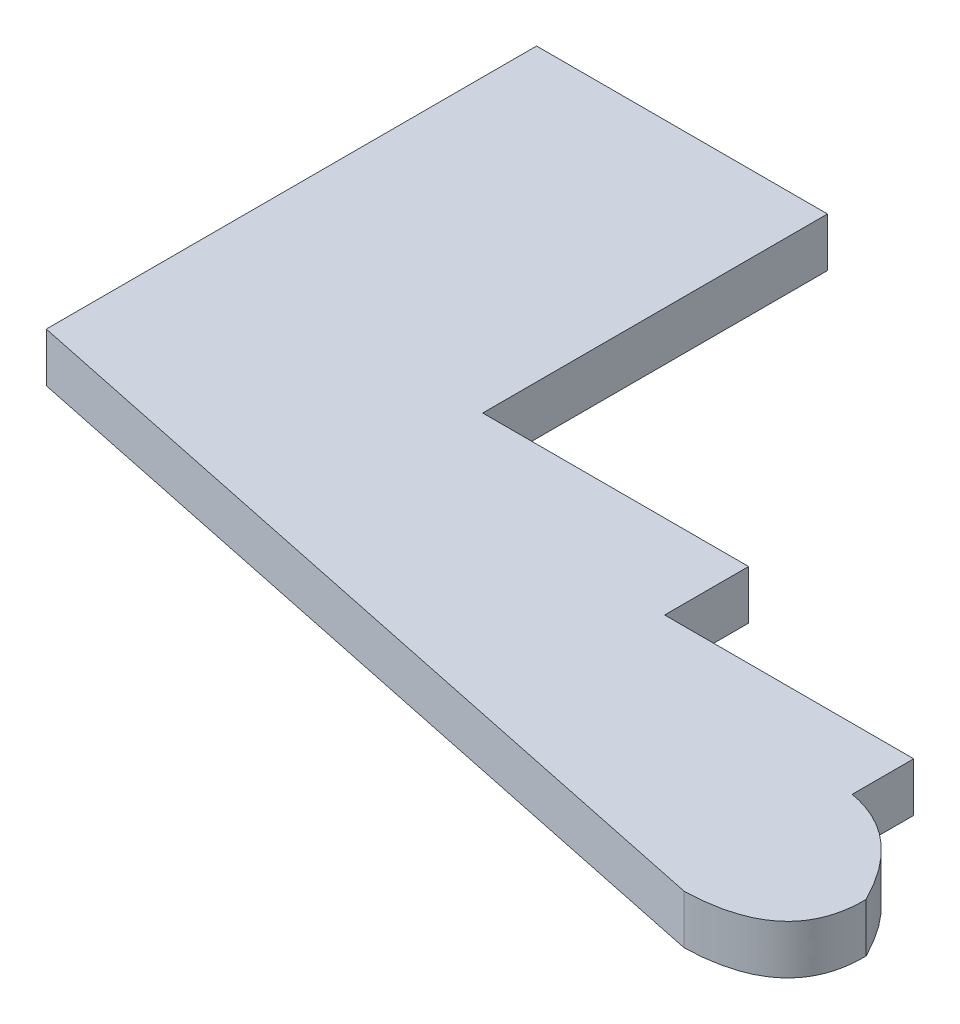
from build123d import *

# Parameters (mm, degrees)
BOSS_EXTRUDE2_DEPTH = 5.08


with BuildPart() as part:
    # Sketch2 → Boss-Extrude2 (new body)
    with BuildSketch(Plane(origin=(0, 0, 0), x_dir=(1, 0, 0), z_dir=(0, 1, 0))):
        with BuildLine():
            Line((0, 0), (30.130673801, 0))
            Line((30.130673801, 0), (30.130673801, -29.621601631))
            Line((30.130673801, -29.621601631), (30.130673801, -35.708970709))
            Line((30.130673801, -35.708970709), (57.668772007, -35.708970709))
            Line((57.668772007, -35.708970709), (57.668772007, -44.405212247))
            Line((57.668772007, -44.405212247), (83.467621906, -44.405212247))
            Line((83.467621906, -44.405212247), (83.467621906, -50.782456043))
            add(Edge.make_bspline(
                [(93.613237035, -59.478697582), (89.75401012, -51.849955928), (83.467621906, -50.782456043)],
                knots=[0, 0, 0, 0.754491666, 0.754491666, 0.754491666], degree=2))
            add(Edge.make_bspline(
                [(83.467621906, -68.17493912), (93.746562006, -67.908588045), (93.613237035, -59.478697582)],
                knots=[0, 0, 0, 1, 1, 1], degree=2))
            Line((83.467621906, -68.17493912), (0, -50.782456043))
            Line((0, -50.782456043), (0, 0))
        make_face()
    extrude(amount=BOSS_EXTRUDE2_DEPTH)


solid = part.part
